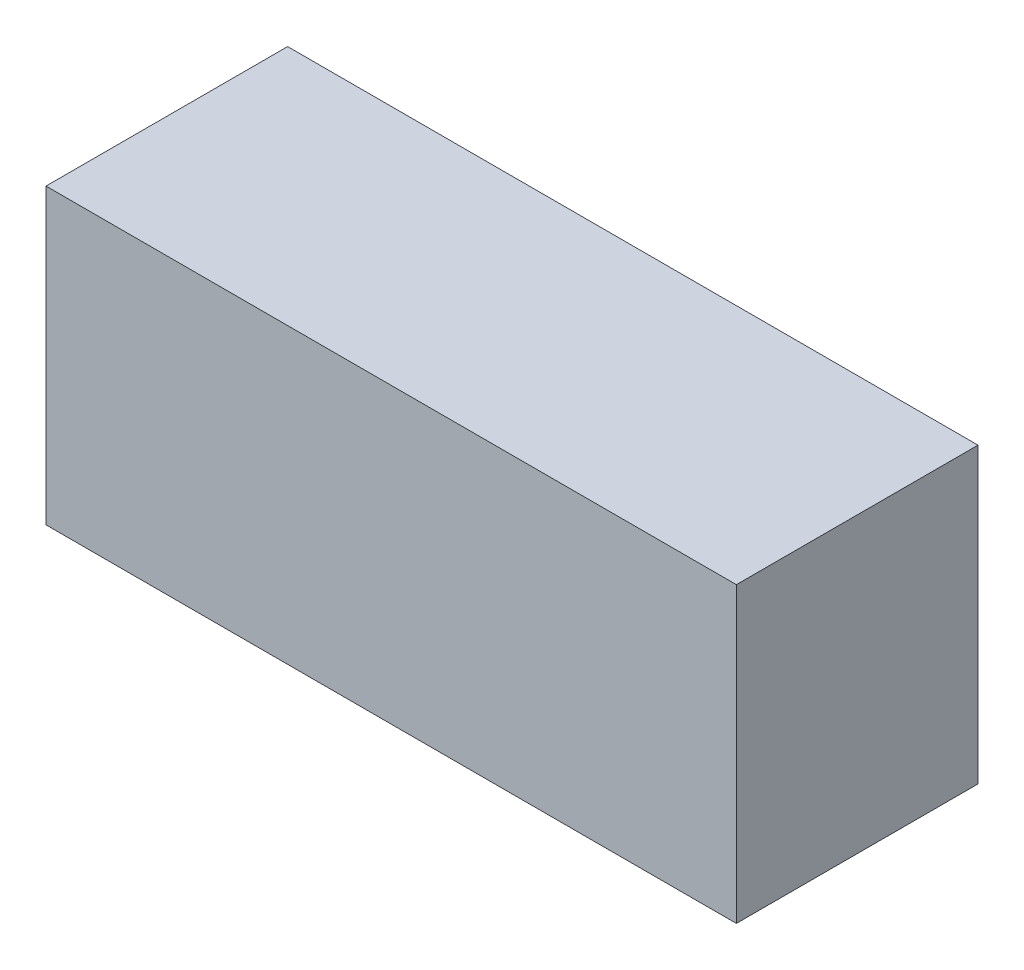
from build123d import *

# Parameters (mm, degrees)
SKETCH_1_W      = 400
SKETCH_1_H      = 170
EXTRUDE_1_DEPTH = 140


with BuildPart() as part:
    # 草图1 → 凸台-拉伸1 (new body)
    with BuildSketch(Plane.XY):
        with Locations((200, 85)):
            Rectangle(SKETCH_1_W, SKETCH_1_H)
    extrude(amount=EXTRUDE_1_DEPTH)


solid = part.part
